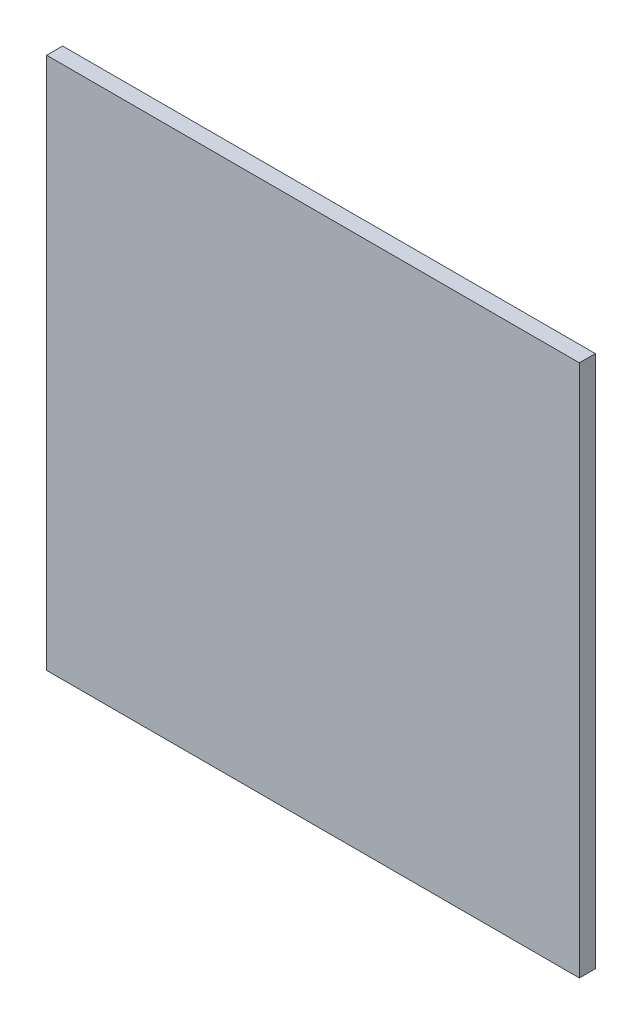
from build123d import *

# Parameters (mm, degrees)
SKETCH2_W           = 100
SKETCH2_H           = 100
BOSS_EXTRUDE1_DEPTH = 3


with BuildPart() as part:
    # Sketch2 → Boss-Extrude1 (new body)
    with BuildSketch(Plane.XY):
        with Locations((23.968906076, -56.292457263)):
            Rectangle(SKETCH2_W, SKETCH2_H)
    extrude(amount=BOSS_EXTRUDE1_DEPTH)


solid = part.part
